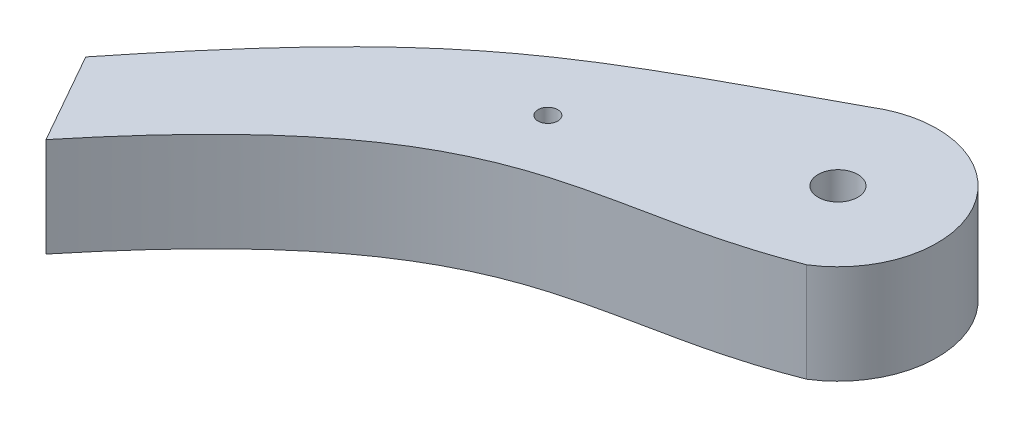
from build123d import *

# Parameters (mm, degrees)
SKETCH1_R           = 2
SKETCH1_R_2         = 1
BOSS_EXTRUDE1_DEPTH = 10


with BuildPart() as part:
    # Sketch1 → Boss-Extrude1 (new body)
    with BuildSketch(Plane(origin=(0, 0, 0), x_dir=(1, 0, 0), z_dir=(0, 1, 0))):
        with BuildLine():
            Line((-43.980681388, -35.900071191), (-49.199029144, -26.673592784))
            add(Edge.make_bspline(
                [(-49.199029144, -26.673592784), (-31.845281334, -4.900517613), (-24.966664763, -2.13955382), (-5.316002055, 8.469954082)],
                knots=[0, 0, 0, 0, 1, 1, 1, 1], degree=3))
            ThreePointArc((-5.316002055, 8.469954082), (8.469954082, 5.316002055), (5.316002055, -8.469954082))
            add(Edge.make_bspline(
                [(-43.980681388, -35.900071191), (-21.812551229, -8.740215805), (-12.045610471, -15.281217208), (5.316002055, -8.469954082)],
                knots=[0, 0, 0, 0, 1, 1, 1, 1], degree=3))
        make_face()
        Circle(SKETCH1_R, mode=Mode.SUBTRACT)
        with Locations((-20.788744537, -8.469954082)):
            Circle(SKETCH1_R_2, mode=Mode.SUBTRACT)
    extrude(amount=BOSS_EXTRUDE1_DEPTH)


solid = part.part
